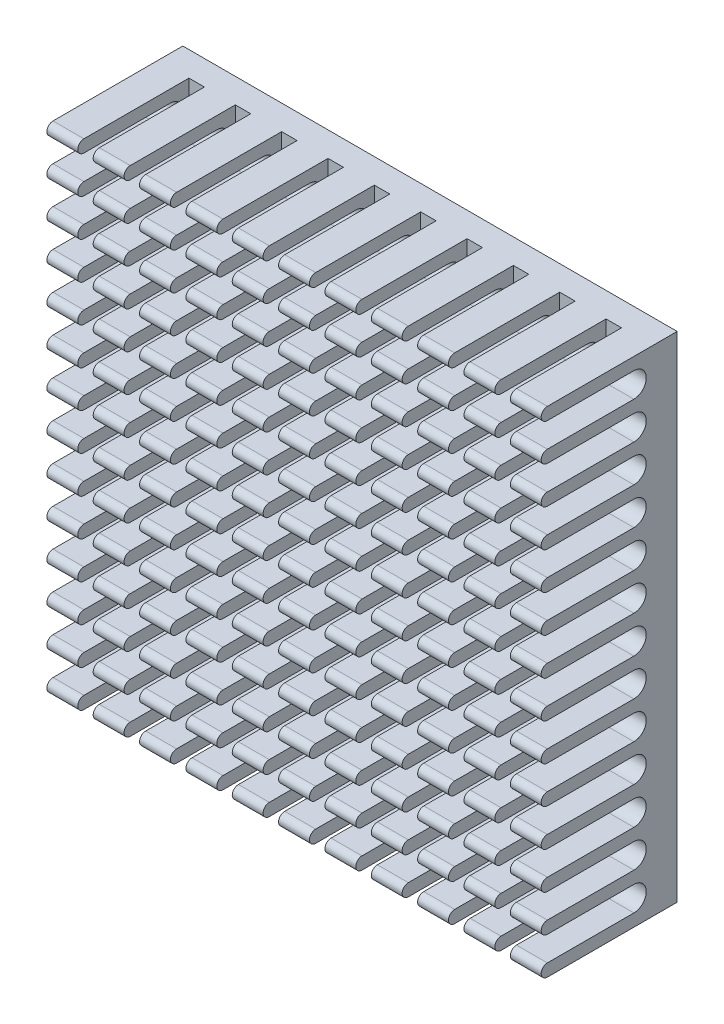
from build123d import *

# Parameters (mm, degrees)
SKETCH1_W               = 40
SKETCH1_H               = 40
BOSS_EXTRUDE1_DEPTH     = 11
CUT_EXTRUDE1_DEPTH      = 21
CUT_EXTRUDE1_DEPTH_BACK = 21
SKETCH3_W               = 1.25
SKETCH3_H               = 9
CUT_EXTRUDE2_DEPTH      = 21
CUT_EXTRUDE2_DEPTH_BACK = 21


with BuildPart() as part:
    # Sketch1 → Boss-Extrude1 (new body)
    with BuildSketch(Plane(origin=(0, 0, 0), x_dir=(0, 1, 0), z_dir=(0, 0, 1))):
        Rectangle(SKETCH1_W, SKETCH1_H)
    extrude(amount=BOSS_EXTRUDE1_DEPTH)

    # Sketch2 → Cut-Extrude1 (cut, two sides)
    with BuildSketch(Plane.YZ) as cut_extrude1_sk:
        with BuildLine():
            ThreePointArc((-19.5, 11), (-19.146446609, 10.853553391), (-19, 10.5))
            Line((-19, 10.5), (-19, 3.5))
            ThreePointArc((-19, 3.5), (-18, 2.5), (-17, 3.5))
            Line((-17, 3.5), (-17, 10.5))
            ThreePointArc((-17, 10.5), (-16.853553391, 10.853553391), (-16.5, 11))
            Line((-16.5, 11), (-19.5, 11))
        make_face()
        with BuildLine():
            Line((-13.5, 11), (-16.5, 11))
            ThreePointArc((-16.5, 11), (-16.146446609, 10.853553391), (-16, 10.5))
            Line((-16, 10.5), (-16, 3.5))
            ThreePointArc((-16, 3.5), (-15, 2.5), (-14, 3.5))
            Line((-14, 3.5), (-14, 10.5))
            ThreePointArc((-14, 10.5), (-13.853553391, 10.853553391), (-13.5, 11))
        make_face()
        with BuildLine():
            Line((-10.5, 11), (-13.5, 11))
            ThreePointArc((-13.5, 11), (-13.146446609, 10.853553391), (-13, 10.5))
            Line((-13, 10.5), (-13, 3.5))
            ThreePointArc((-13, 3.5), (-12, 2.5), (-11, 3.5))
            Line((-11, 3.5), (-11, 10.5))
            ThreePointArc((-11, 10.5), (-10.853553391, 10.853553391), (-10.5, 11))
        make_face()
        with BuildLine():
            ThreePointArc((-20, 10.5), (-19.853553391, 10.853553391), (-19.5, 11))
            Line((-19.5, 11), (-20, 11))
            Line((-20, 11), (-20, 10.5))
        make_face()
        with BuildLine():
            Line((-7.5, 11), (-10.5, 11))
            ThreePointArc((-10.5, 11), (-10.146446609, 10.853553391), (-10, 10.5))
            Line((-10, 10.5), (-10, 3.5))
            ThreePointArc((-10, 3.5), (-9, 2.5), (-8, 3.5))
            Line((-8, 3.5), (-8, 10.5))
            ThreePointArc((-8, 10.5), (-7.853553391, 10.853553391), (-7.5, 11))
        make_face()
        with BuildLine():
            Line((-4.499999999, 11), (-7.5, 11))
            ThreePointArc((-7.5, 11), (-7.146446609, 10.853553391), (-7, 10.5))
            Line((-7, 10.5), (-7, 3.5))
            ThreePointArc((-7, 3.5), (-6, 2.5), (-5, 3.5))
            Line((-5, 3.5), (-5, 10.5))
            ThreePointArc((-5, 10.5), (-4.85355339, 10.853553391), (-4.499999999, 11))
        make_face()
        with BuildLine():
            Line((-1.5, 11), (-4.499999999, 11))
            ThreePointArc((-4.499999999, 11), (-4.146446609, 10.85355339), (-4, 10.5))
            Line((-4, 10.5), (-4, 3.5))
            ThreePointArc((-4, 3.5), (-3, 2.5), (-2, 3.5))
            Line((-2, 3.5), (-2, 10.5))
            ThreePointArc((-2, 10.5), (-1.85355339, 10.853553391), (-1.5, 11))
        make_face()
        with BuildLine():
            Line((1.500000001, 11), (-1.5, 11))
            ThreePointArc((-1.5, 11), (-1.146446609, 10.85355339), (-1, 10.5))
            Line((-1, 10.5), (-1, 3.5))
            ThreePointArc((-1, 3.5), (0, 2.5), (1, 3.5))
            Line((1, 3.5), (1, 10.5))
            ThreePointArc((1, 10.5), (1.14644661, 10.853553391), (1.500000001, 11))
        make_face()
        with BuildLine():
            Line((4.5, 11), (1.500000001, 11))
            ThreePointArc((1.500000001, 11), (1.853553391, 10.85355339), (2, 10.5))
            Line((2, 10.5), (2, 3.5))
            ThreePointArc((2, 3.5), (3, 2.5), (4, 3.5))
            Line((4, 3.5), (4, 10.5))
            ThreePointArc((4, 10.5), (4.146446609, 10.853553391), (4.5, 11))
        make_face()
        with BuildLine():
            Line((7.5, 11), (4.5, 11))
            ThreePointArc((4.5, 11), (4.853553391, 10.853553391), (5, 10.5))
            Line((5, 10.5), (5, 3.5))
            ThreePointArc((5, 3.5), (6, 2.5), (7, 3.5))
            Line((7, 3.5), (7, 10.5))
            ThreePointArc((7, 10.5), (7.146446609, 10.853553391), (7.5, 11))
        make_face()
        with BuildLine():
            Line((10.5, 11), (7.5, 11))
            ThreePointArc((7.5, 11), (7.853553391, 10.853553391), (8, 10.5))
            Line((8, 10.5), (8, 3.5))
            ThreePointArc((8, 3.5), (9, 2.5), (10, 3.5))
            Line((10, 3.5), (10, 10.5))
            ThreePointArc((10, 10.5), (10.146446609, 10.853553391), (10.5, 11))
        make_face()
        with BuildLine():
            Line((13.500000008, 11), (10.5, 11))
            ThreePointArc((10.5, 11), (10.853553391, 10.853553391), (11, 10.5))
            Line((11, 10.5), (11, 3.5))
            ThreePointArc((11, 3.5), (12, 2.5), (13, 3.5))
            Line((13, 3.5), (13, 10.5))
            ThreePointArc((13, 10.5), (13.146446612, 10.853553394), (13.500000008, 11))
        make_face()
        with BuildLine():
            Line((16.49999999, 11), (13.500000008, 11))
            ThreePointArc((13.500000008, 11), (13.853553394, 10.853553388), (14, 10.5))
            Line((14, 10.5), (14, 3.5))
            ThreePointArc((14, 3.5), (15, 2.5), (16, 3.5))
            Line((16, 3.5), (16, 10.5))
            ThreePointArc((16, 10.5), (16.146446606, 10.853553387), (16.49999999, 11))
        make_face()
        with BuildLine():
            Line((19.5, 11), (16.49999999, 11))
            ThreePointArc((16.49999999, 11), (16.853553387, 10.853553394), (17, 10.5))
            Line((17, 10.5), (17, 3.5))
            ThreePointArc((17, 3.5), (18, 2.5), (19, 3.5))
            Line((19, 3.5), (19, 10.5))
            ThreePointArc((19, 10.5), (19.146446609, 10.853553391), (19.5, 11))
        make_face()
        with BuildLine():
            Line((20, 11), (19.5, 11))
            ThreePointArc((19.5, 11), (19.853553391, 10.853553391), (20, 10.5))
            Line((20, 10.5), (20, 11))
        make_face()
    extrude(amount=CUT_EXTRUDE1_DEPTH, mode=Mode.SUBTRACT)
    extrude(cut_extrude1_sk.sketch, amount=-CUT_EXTRUDE1_DEPTH_BACK, mode=Mode.SUBTRACT)

    # Sketch3 → Cut-Extrude2 (cut, two sides)
    with BuildSketch(Plane(origin=(0, 0, 0), x_dir=(-1, 0, 0), z_dir=(0, 1, 0))) as cut_extrude2_sk:
        with Locations((-16.875, 6.5)):
            Rectangle(SKETCH3_W, SKETCH3_H)
        with Locations((-13.125, 6.5)):
            Rectangle(SKETCH3_W, SKETCH3_H)
        with Locations((-9.375, 6.5)):
            Rectangle(SKETCH3_W, SKETCH3_H)
        with Locations((-5.625, 6.5)):
            Rectangle(SKETCH3_W, SKETCH3_H)
        with Locations((-1.875, 6.5)):
            Rectangle(SKETCH3_W, SKETCH3_H)
        with Locations((1.875, 6.5)):
            Rectangle(SKETCH3_W, SKETCH3_H)
        with Locations((5.625, 6.5)):
            Rectangle(SKETCH3_W, SKETCH3_H)
        with Locations((9.375, 6.5)):
            Rectangle(SKETCH3_W, SKETCH3_H)
        with Locations((13.125, 6.5)):
            Rectangle(SKETCH3_W, SKETCH3_H)
        with Locations((16.875, 6.5)):
            Rectangle(SKETCH3_W, SKETCH3_H)
    extrude(amount=CUT_EXTRUDE2_DEPTH, mode=Mode.SUBTRACT)
    extrude(cut_extrude2_sk.sketch, amount=-CUT_EXTRUDE2_DEPTH_BACK, mode=Mode.SUBTRACT)


solid = part.part
